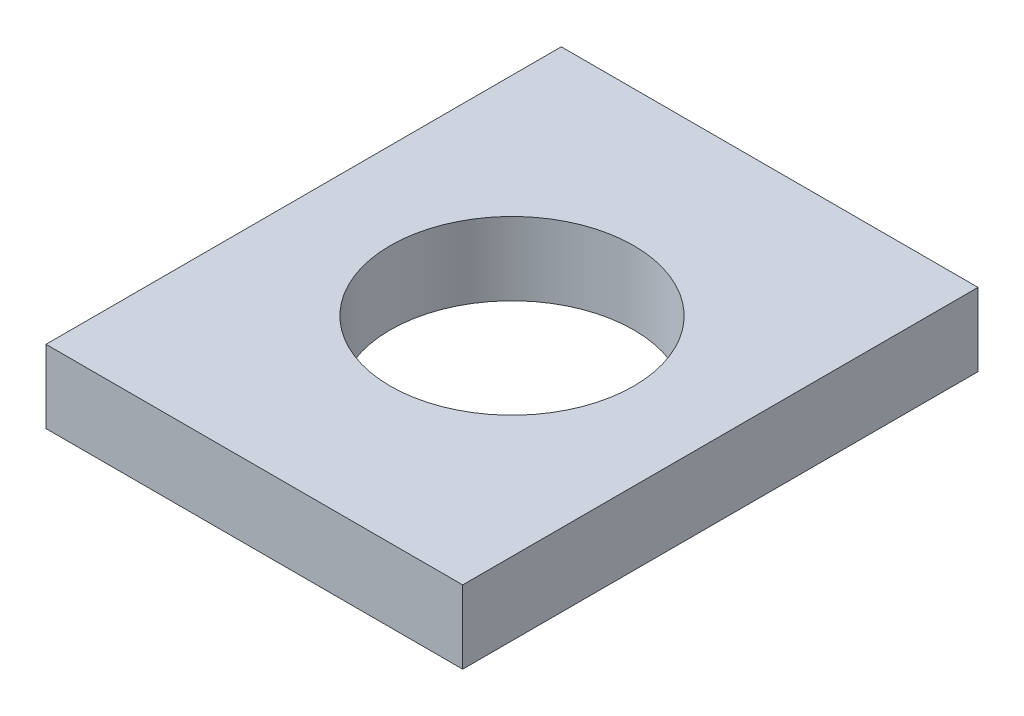
from build123d import *

# Parameters (mm, degrees)
SKETCH1_W           = 102.7
SKETCH1_H           = 127
BOSS_EXTRUDE1_DEPTH = 18
SKETCH2_R           = 30
CUT_EXTRUDE1_DEPTH  = 19


with BuildPart() as part:
    # Sketch1 → Boss-Extrude1 (new body)
    with BuildSketch(Plane(origin=(0, 0, 0), x_dir=(1, 0, 0), z_dir=(0, 1, 0))):
        Rectangle(SKETCH1_W, SKETCH1_H)
    extrude(amount=BOSS_EXTRUDE1_DEPTH)

    # Sketch2 → Cut-Extrude1 (cut, through all)
    with BuildSketch(Plane(origin=(0, 18, 0), x_dir=(1, 0, 0), z_dir=(0, 1, 0))):
        Circle(SKETCH2_R)
    extrude(amount=-CUT_EXTRUDE1_DEPTH, mode=Mode.SUBTRACT)


solid = part.part
